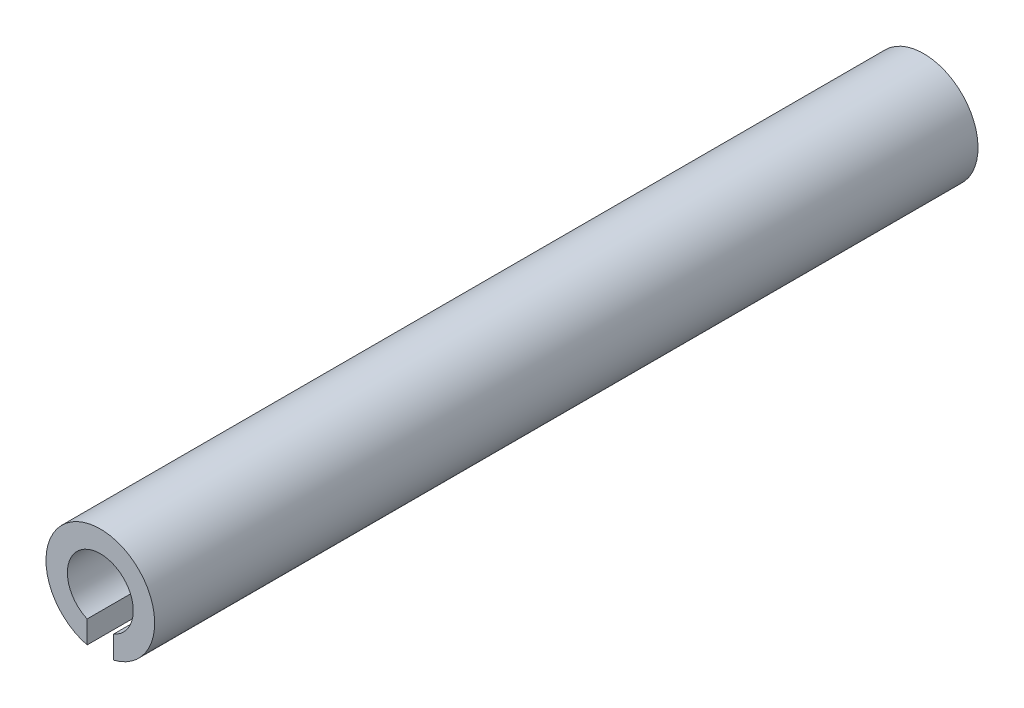
from build123d import *

# Parameters (mm, degrees)
DOWEL_BODY_DEPTH = 25


with BuildPart() as part:
    # Sketch1 → dowel_body (new body)
    with BuildSketch(Plane.XY):
        with BuildLine():
            Line((-0.4, -1.600781059), (-0.4, -0.916515139))
            ThreePointArc((-0.4, -0.916515139), (-0.547722558, 0.836660027), (1, 0))
            ThreePointArc((1, 0), (0.836660027, -0.547722558), (0.4, -0.916515139))
            Line((0.4, -0.916515139), (0.4, -1.600781059))
            ThreePointArc((0.4, -1.600781059), (1.30048068, -1.015504801), (1.65, 0))
            ThreePointArc((1.65, 0), (-1.015504801, 1.30048068), (-0.4, -1.600781059))
        make_face()
    extrude(amount=DOWEL_BODY_DEPTH)


solid = part.part
